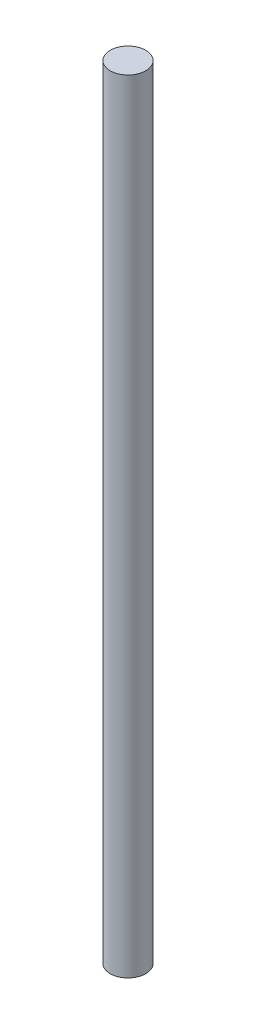
from build123d import *

# Parameters (mm, degrees)
SKETCH1_R           = 3.175
BOSS_EXTRUDE1_DEPTH = 139.7


with BuildPart() as part:
    # Sketch1 → Boss-Extrude1 (new body)
    with BuildSketch(Plane(origin=(0, 0, 0), x_dir=(1, 0, 0), z_dir=(0, 1, 0))):
        Circle(SKETCH1_R)
    extrude(amount=BOSS_EXTRUDE1_DEPTH)


solid = part.part
